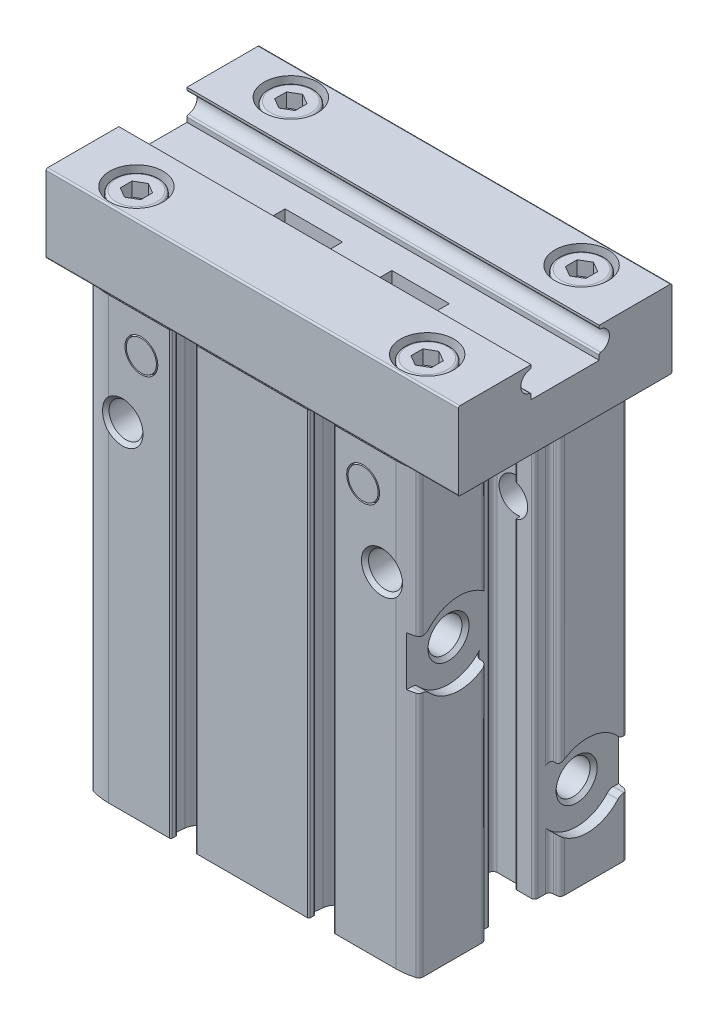
from build123d import *

# Parameters (mm, degrees)
BOSS_EXTRUDE1_DEPTH      = 53.6
HOLE1_D                  = 4.134
HOLE1_DEPTH              = 10.4
HOLE1_CSINK_D            = 5
HOLE1_CSINK_ANGLE        = 90
CUT_EXTRUDE1_DEPTH       = 1.3
CUT_EXTRUDE2_DEPTH       = 1.3
CUT_EXTRUDE3_DEPTH       = 53.6
CUT_EXTRUDE4_DEPTH       = 53.6
BOSS_EXTRUDE2_DEPTH      = 25.1
BOSS_EXTRUDE2_DEPTH_BACK = 25.1
SKETCH25_R               = 1
BOSS_EXTRUDE3_DEPTH      = 1
CUT_EXTRUDE5_DEPTH       = 53.6
CUT_EXTRUDE6_DEPTH       = 53.6
CUT_EXTRUDE7_DEPTH       = 53.6
CUT_EXTRUDE8_DEPTH       = 53.6
SKETCH32_W               = 2
SKETCH32_H               = 26
SKETCH33_W               = 2
SKETCH33_H               = 26
CUT_EXTRUDE9_DEPTH       = 1
CUT_EXTRUDE9_DEPTH_BACK  = 1
SKETCH36_W               = 7
SKETCH36_H               = 2
CUT_EXTRUDE10_DEPTH      = 1
CUT_EXTRUDE10_DEPTH_BACK = 1
SKETCH37_W               = 7
SKETCH37_H               = 2
CUT_EXTRUDE11_DEPTH      = 1.7
LPATTERN1_COUNT          = 2
LPATTERN1_PITCH          = 18.8
LPATTERN1_COUNT_DIR2     = 2
LPATTERN1_PITCH_DIR2     = 35.4


with BuildPart() as part:
    # Sketch1 → Boss-Extrude1 (new body)
    with BuildSketch(Plane(origin=(0, 0, 0), x_dir=(1, 0, 0), z_dir=(0, 1, 0))):
        with BuildLine():
            Line((-17.5, -13), (17.5, -13))
            ThreePointArc((17.5, -13), (18.582771866, -12.921428777), (19.642857143, -12.687361356))
            ThreePointArc((19.642857143, -12.687361356), (19.900891863, -12.507011085), (20, -12.208203933))
            Line((20, -12.208203933), (20, 12.208203933))
            ThreePointArc((20, 12.208203933), (19.900891863, 12.507011085), (19.642857143, 12.687361356))
            ThreePointArc((19.642857143, 12.687361356), (18.582771866, 12.921428777), (17.5, 13))
            Line((17.5, 13), (-17.5, 13))
            ThreePointArc((-17.5, 13), (-18.582771866, 12.921428777), (-19.642857143, 12.687361356))
            ThreePointArc((-19.642857143, 12.687361356), (-19.900891863, 12.507011085), (-20, 12.208203933))
            Line((-20, 12.208203933), (-20, -12.208203933))
            ThreePointArc((-20, -12.208203933), (-19.900891863, -12.507011085), (-19.642857143, -12.687361356))
            ThreePointArc((-19.642857143, -12.687361356), (-18.582771866, -12.921428777), (-17.5, -13))
        make_face()
    extrude(amount=BOSS_EXTRUDE1_DEPTH)

    # Sketch2 → Cut-Revolve1 (revolve, cut)
    with BuildSketch(Plane(origin=(0, 41, 0), x_dir=(1, 0, 0), z_dir=(0, 1, 0))):
        Polygon((15.8, -2.6), (17.867, -2.6), (17.867, -12.567), (18.3, -13), (15.8, -13), align=None)
    revolve(axis=Axis((15.8, 41, 13), (0, 0, -1)), mode=Mode.SUBTRACT)

    # Sketch3 → Cut-Revolve2 (revolve, cut)
    with BuildSketch(Plane(origin=(0, 41, 0), x_dir=(1, 0, 0), z_dir=(0, 1, 0))):
        Polygon((-15.8, -2.6), (-13.733, -2.6), (-13.733, -12.567), (-13.3, -13), (-15.8, -13), align=None)
    revolve(axis=Axis((-15.8, 41, 13), (0, 0, -1)), mode=Mode.SUBTRACT)

    # Hole1
    with Locations(Plane(origin=(0, 0, -13), x_dir=(-1, 0, 0), z_dir=(0, 0, -1))):
        with Locations((-15.8, 41)):
            CounterSinkHole(HOLE1_D / 2, HOLE1_CSINK_D / 2, depth=HOLE1_DEPTH, counter_sink_angle=HOLE1_CSINK_ANGLE)

    # Sketch6 → Cut-Revolve3 (revolve, cut)
    with BuildSketch(Plane(origin=(0, 41, 0), x_dir=(1, 0, 0), z_dir=(0, 1, 0))):
        Polygon((-15.8, 13), (-13.3, 13), (-13.733, 12.567), (-13.733, 2.6), (-15.8, 2.6), align=None)
    revolve(axis=Axis((-15.8, 41, -2.6), (0, 0, -1)), mode=Mode.SUBTRACT)

    # Sketch7 → Cut-Extrude1 (cut)
    with BuildSketch(Plane(origin=(20, 0, 0), x_dir=(0, 0, -1), z_dir=(1, 0, 0))):
        with BuildLine():
            Line((12.272135955, 7.2), (14, 7.2))
            Line((14, 7.2), (14, 13.2))
            Line((14, 13.2), (12.272135955, 13.2))
            ThreePointArc((12.272135955, 13.2), (11.863887665, 13.287129071), (11.526779962, 13.533333333))
            ThreePointArc((11.526779962, 13.533333333), (2.8, 10.2), (11.526779962, 6.866666667))
            ThreePointArc((11.526779962, 6.866666667), (11.863887665, 7.112870929), (12.272135955, 7.2))
        make_face()
    extrude(amount=-CUT_EXTRUDE1_DEPTH, mode=Mode.SUBTRACT)

    # Sketch8 → Cut-Extrude2 (cut)
    with BuildSketch(Plane(origin=(20, 0, 0), x_dir=(0, 0, -1), z_dir=(1, 0, 0))):
        with BuildLine():
            Line((-14, 30), (-12.272135955, 30))
            ThreePointArc((-12.272135955, 30), (-11.863887665, 29.912870929), (-11.526779962, 29.666666667))
            ThreePointArc((-11.526779962, 29.666666667), (-2.8, 33), (-11.526779962, 36.333333333))
            ThreePointArc((-11.526779962, 36.333333333), (-11.863887665, 36.087129071), (-12.272135955, 36))
            Line((-12.272135955, 36), (-14, 36))
            Line((-14, 36), (-14, 30))
        make_face()
    extrude(amount=-CUT_EXTRUDE2_DEPTH, mode=Mode.SUBTRACT)

    # Sketch9 → Cut-Revolve4 (revolve, cut)
    with BuildSketch(Plane.XY.offset(-7.8)):
        Polygon((12.7, 10.2), (12.7, 12.267), (18.267, 12.267), (18.7, 12.7), (18.7, 10.2), align=None)
    revolve(axis=Axis((18.7, 10.2, -7.8), (-1, 0, 0)), mode=Mode.SUBTRACT)

    # Sketch10 → Cut-Revolve5 (revolve, cut)
    with BuildSketch(Plane.XY.offset(7.8)):
        Polygon((12.7, 33), (12.7, 35.067), (18.267, 35.067), (18.7, 35.5), (18.7, 33), align=None)
    revolve(axis=Axis((18.7, 33, 7.8), (-1, 0, 0)), mode=Mode.SUBTRACT)

    # Sketch11 → Cut-Revolve6 (revolve, cut)
    with BuildSketch(Plane(origin=(0, 33, 0), x_dir=(1, 0, 0), z_dir=(0, 1, 0))):
        with BuildLine():
            Line((-20, 7), (-20, 11.2))
            ThreePointArc((-20, 11.2), (-19.941421356, 11.058578644), (-19.8, 11))
            Line((-19.8, 11), (-18.7, 11))
            Line((-18.7, 11), (-18.7, 7))
            Line((-18.7, 7), (-20, 7))
        make_face()
    revolve(axis=Axis((-18.7, 33, -7), (-1, 0, 0)), mode=Mode.SUBTRACT)

    # Sketch12 → Cut-Revolve7 (revolve, cut)
    with BuildSketch(Plane(origin=(0, 33, 0), x_dir=(1, 0, 0), z_dir=(0, 1, 0))):
        with BuildLine():
            Line((-20, -7), (-20, -2.8))
            ThreePointArc((-20, -2.8), (-19.941421356, -2.941421356), (-19.8, -3))
            Line((-19.8, -3), (-18.7, -3))
            Line((-18.7, -3), (-18.7, -7))
            Line((-18.7, -7), (-20, -7))
        make_face()
    revolve(axis=Axis((-18.7, 33, 7), (-1, 0, 0)), mode=Mode.SUBTRACT)

    # Sketch13 → Cut-Revolve8 (revolve, cut)
    with BuildSketch(Plane(origin=(0, 33, 0), x_dir=(1, 0, 0), z_dir=(0, 1, 0))):
        Polygon((-18.7, 7), (-18.7, 9.5), (-18.267, 9.067), (-10.7, 9.067), (-10.7, 7), align=None)
    revolve(axis=Axis((-10.7, 33, -7), (-1, 0, 0)), mode=Mode.SUBTRACT)

    # Sketch14 → Cut-Revolve9 (revolve, cut)
    with BuildSketch(Plane(origin=(0, 33, 0), x_dir=(1, 0, 0), z_dir=(0, 1, 0))):
        Polygon((-18.7, -7), (-18.7, -4.5), (-18.267, -4.933), (-10.7, -4.933), (-10.7, -7), align=None)
    revolve(axis=Axis((-10.7, 33, 7), (-1, 0, 0)), mode=Mode.SUBTRACT)

    # Sketch15 → Cut-Revolve10 (revolve, cut)
    with BuildSketch(Plane(origin=(0, 23, 0), x_dir=(1, 0, 0), z_dir=(0, 1, 0))):
        Polygon((-20, 8), (-20, 10.2), (-19.8, 10), (-16, 10), (-16, 8), align=None)
    revolve(axis=Axis((-16, 23, -8), (-1, 0, 0)), mode=Mode.SUBTRACT)

    # Sketch16 → Cut-Revolve11 (revolve, cut)
    with BuildSketch(Plane(origin=(0, 23, 0), x_dir=(1, 0, 0), z_dir=(0, 1, 0))):
        Polygon((-20, -8), (-20, -5.8), (-19.8, -6), (-16, -6), (-16, -8), align=None)
    revolve(axis=Axis((-16, 23, 8), (-1, 0, 0)), mode=Mode.SUBTRACT)

    # Sketch17 → Cut-Extrude3 (cut)
    with BuildSketch(Plane(origin=(0, 0, 0), x_dir=(1, 0, 0), z_dir=(0, 1, 0))):
        with BuildLine():
            Line((-19.5, -4.5), (-19.2, -4.5))
            ThreePointArc((-19.2, -4.5), (-18.846446609, -4.353553391), (-18.7, -4))
            Line((-18.7, -4), (-18.7, -3.075))
            ThreePointArc((-18.7, -3.075), (-18.582842712, -2.792157288), (-18.3, -2.675))
            Line((-18.3, -2.675), (-16.55, -2.675))
            ThreePointArc((-16.55, -2.675), (-16.408578644, -2.733578644), (-16.35, -2.875))
            Line((-16.35, -2.875), (-16.35, -3.125))
            ThreePointArc((-16.35, -3.125), (-16.291421356, -3.266421356), (-16.15, -3.325))
            Line((-16.15, -3.325), (-13.5, -3.325))
            ThreePointArc((-13.5, -3.325), (-13.146446609, -3.178553391), (-13, -2.825))
            Line((-13, -2.825), (-13, 2.825))
            ThreePointArc((-13, 2.825), (-13.146446609, 3.178553391), (-13.5, 3.325))
            Line((-13.5, 3.325), (-16.15, 3.325))
            ThreePointArc((-16.15, 3.325), (-16.291421356, 3.266421356), (-16.35, 3.125))
            Line((-16.35, 3.125), (-16.35, 2.875))
            ThreePointArc((-16.35, 2.875), (-16.408578644, 2.733578644), (-16.55, 2.675))
            Line((-16.55, 2.675), (-18.3, 2.675))
            ThreePointArc((-18.3, 2.675), (-18.582842712, 2.792157288), (-18.7, 3.075))
            Line((-18.7, 3.075), (-18.7, 4))
            ThreePointArc((-18.7, 4), (-18.846446609, 4.353553391), (-19.2, 4.5))
            Line((-19.2, 4.5), (-19.5, 4.5))
            ThreePointArc((-19.5, 4.5), (-19.853553391, 4.646446609), (-20, 5))
            Line((-20, 5), (-20, -5))
            ThreePointArc((-20, -5), (-19.853553391, -4.646446609), (-19.5, -4.5))
        make_face()
    extrude(amount=CUT_EXTRUDE3_DEPTH, mode=Mode.SUBTRACT)

    # Sketch18 → Cut-Extrude4 (cut)
    with BuildSketch(Plane(origin=(0, 0, 0), x_dir=(1, 0, 0), z_dir=(0, 1, 0))):
        with BuildLine():
            Line((13, 2.825), (13, -2.825))
            ThreePointArc((13, -2.825), (13.146446609, -3.178553391), (13.5, -3.325))
            Line((13.5, -3.325), (16.15, -3.325))
            ThreePointArc((16.15, -3.325), (16.291421356, -3.266421356), (16.35, -3.125))
            Line((16.35, -3.125), (16.35, -2.875))
            ThreePointArc((16.35, -2.875), (16.408578644, -2.733578644), (16.55, -2.675))
            Line((16.55, -2.675), (18.3, -2.675))
            ThreePointArc((18.3, -2.675), (18.582842712, -2.792157288), (18.7, -3.075))
            Line((18.7, -3.075), (18.7, -4))
            ThreePointArc((18.7, -4), (18.846446609, -4.353553391), (19.2, -4.5))
            Line((19.2, -4.5), (19.5, -4.5))
            ThreePointArc((19.5, -4.5), (19.853553391, -4.646446609), (20, -5))
            Line((20, -5), (20, 5))
            ThreePointArc((20, 5), (19.853553391, 4.646446609), (19.5, 4.5))
            Line((19.5, 4.5), (19.2, 4.5))
            ThreePointArc((19.2, 4.5), (18.846446609, 4.353553391), (18.7, 4))
            Line((18.7, 4), (18.7, 3.075))
            ThreePointArc((18.7, 3.075), (18.582842712, 2.792157288), (18.3, 2.675))
            Line((18.3, 2.675), (16.55, 2.675))
            ThreePointArc((16.55, 2.675), (16.408578644, 2.733578644), (16.35, 2.875))
            Line((16.35, 2.875), (16.35, 3.125))
            ThreePointArc((16.35, 3.125), (16.291421356, 3.266421356), (16.15, 3.325))
            Line((16.15, 3.325), (13.5, 3.325))
            ThreePointArc((13.5, 3.325), (13.146446609, 3.178553391), (13, 2.825))
        make_face()
    extrude(amount=CUT_EXTRUDE4_DEPTH, mode=Mode.SUBTRACT)

    # Sketch19 → Boss-Extrude2 (add, two sides: drawn at the far end of the back side and taken through both)
    with BuildSketch(Plane(origin=(0, 0, 0), x_dir=(0, 0, -1), z_dir=(1, 0, 0)).offset(-BOSS_EXTRUDE2_DEPTH_BACK)):
        with BuildLine():
            Line((-13, 62.9), (-13, 53.8))
            ThreePointArc((-13, 53.8), (-12.941421356, 53.658578644), (-12.8, 53.6))
            Line((-12.8, 53.6), (12.8, 53.6))
            ThreePointArc((12.8, 53.6), (12.941421356, 53.658578644), (13, 53.8))
            Line((13, 53.8), (13, 62.9))
            ThreePointArc((13, 62.9), (12.941421356, 63.041421356), (12.8, 63.1))
            Line((12.8, 63.1), (4.15, 63.1))
            Line((4.15, 63.1), (4.15, 62.836140662))
            ThreePointArc((4.15, 62.836140662), (4.199140394, 62.704834229), (4.322413793, 62.638052295))
            ThreePointArc((4.322413793, 62.638052295), (5.4, 61.4), (4.322413793, 60.161947705))
            ThreePointArc((4.322413793, 60.161947705), (4.199140394, 60.095165771), (4.15, 59.963859338))
            Line((4.15, 59.963859338), (4.15, 59.4))
            Line((4.15, 59.4), (-4.15, 59.4))
            Line((-4.15, 59.4), (-4.15, 59.963859338))
            ThreePointArc((-4.15, 59.963859338), (-4.199140394, 60.095165771), (-4.322413793, 60.161947705))
            ThreePointArc((-4.322413793, 60.161947705), (-5.4, 61.4), (-4.322413793, 62.638052295))
            ThreePointArc((-4.322413793, 62.638052295), (-4.199140394, 62.704834229), (-4.15, 62.836140662))
            Line((-4.15, 62.836140662), (-4.15, 63.1))
            Line((-4.15, 63.1), (-12.8, 63.1))
            ThreePointArc((-12.8, 63.1), (-12.941421356, 63.041421356), (-13, 62.9))
        make_face()
    extrude(amount=BOSS_EXTRUDE2_DEPTH + BOSS_EXTRUDE2_DEPTH_BACK)

    # Sketch20 → Cut-Revolve12 (revolve, cut)
    with BuildSketch(Plane.XY.offset(8.3)):
        Polygon((15, 10), (17.067, 10), (17.067, 0.433), (17.5, 0), (15, 0), align=None)
    revolve(axis=Axis((15, 0, 8.3), (0, 1, 0)), mode=Mode.SUBTRACT)

    # Sketch21 → Cut-Revolve13 (revolve, cut)
    with BuildSketch(Plane.XY.offset(-8.3)):
        Polygon((-15, 10), (-12.933, 10), (-12.933, 0.433), (-12.5, 0), (-15, 0), align=None)
    revolve(axis=Axis((-15, 0, -8.3), (0, 1, 0)), mode=Mode.SUBTRACT)

    # Sketch22 → Cut-Revolve14 (revolve, cut)
    with BuildSketch(Plane.XY.offset(8.5)):
        Polygon((-15.5, 4), (-13.5, 4), (-13.5, 0.2), (-13.3, 0), (-15.5, 0), align=None)
    revolve(axis=Axis((-15.5, 0, 8.5), (0, 1, 0)), mode=Mode.SUBTRACT)

    # Sketch23 → Cut-Revolve15 (revolve, cut)
    with BuildSketch(Plane.XY.offset(-8.5)):
        Polygon((15.5, 4), (17.5, 4), (17.5, 0.2), (17.7, 0), (15.5, 0), align=None)
    revolve(axis=Axis((15.5, 0, -8.5), (0, 1, 0)), mode=Mode.SUBTRACT)

    # Sketch24 → Cut-Revolve16 (revolve, cut)
    with BuildSketch(Plane.XY):
        Polygon((0, 4), (11, 4), (11, 3), (10.5, 3), (10.5, 0.4), (10.730940108, 0), (0, 0), align=None)
    revolve(axis=Axis((0, 0, 0), (0, 1, 0)), mode=Mode.SUBTRACT)

    # Sketch25 → Boss-Extrude3 (add)
    with BuildSketch(Plane(origin=(0, 3, 0), x_dir=(1, 0, 0), z_dir=(0, 1, 0))):
        with BuildLine():
            Line((10.73498952, -2.4), (6.41641989, -2.4))
            ThreePointArc((6.41641989, -2.4), (5.922520907, -3.569763083), (5.243096089, -4.642453063))
            Line((5.243096089, -4.642453063), (6.438731142, -5.701117546))
            ThreePointArc((6.438731142, -5.701117546), (-8.6, 0), (6.438731142, 5.701117546))
            Line((6.438731142, 5.701117546), (5.243096089, 4.642453063))
            ThreePointArc((5.243096089, 4.642453063), (5.922520907, 3.569763083), (6.41641989, 2.4))
            Line((6.41641989, 2.4), (10.73498952, 2.4))
            ThreePointArc((10.73498952, 2.4), (-11, 0), (10.73498952, -2.4))
        make_face()
        with Locations((7.736278175, 4.4)):
            Circle(SKETCH25_R, mode=Mode.SUBTRACT)
        with Locations((7.736278175, -4.4)):
            Circle(SKETCH25_R, mode=Mode.SUBTRACT)
    extrude(amount=BOSS_EXTRUDE3_DEPTH)

    # Sketch26 → Cut-Revolve17 (revolve, cut)
    with BuildSketch(Plane(origin=(0, 16, 0), x_dir=(1, 0, 0), z_dir=(0, 1, 0))):
        Polygon((14.2, 13), (16.4, 13), (16.2, 12.8), (16.2, 9), (14.2, 9), align=None)
    revolve(axis=Axis((14.2, 16, -9), (0, 0, -1)), mode=Mode.SUBTRACT)

    # Sketch27 → Cut-Revolve18 (revolve, cut)
    with BuildSketch(Plane(origin=(0, 16, 0), x_dir=(1, 0, 0), z_dir=(0, 1, 0))):
        Polygon((-14.2, 13), (-12, 13), (-12.2, 12.8), (-12.2, 9), (-14.2, 9), align=None)
    revolve(axis=Axis((-14.2, 16, -9), (0, 0, -1)), mode=Mode.SUBTRACT)

    # Sketch28 → Cut-Extrude5 (cut)
    with BuildSketch(Plane(origin=(0, 0, 0), x_dir=(1, 0, 0), z_dir=(0, 1, 0))):
        with BuildLine():
            Line((6.512975195, 11.970274713), (6.608936703, 11.010856853))
            ThreePointArc((6.608936703, 11.010856853), (8.4, 9.39), (10.191063297, 11.010856853))
            Line((10.191063297, 11.010856853), (10.287024805, 11.970274713))
            ThreePointArc((10.287024805, 11.970274713), (10.238303244, 12.122142673), (10.094008886, 12.190089754))
            ThreePointArc((10.094008886, 12.190089754), (9.956476095, 12.250712927), (9.9, 12.39))
            Line((9.9, 12.39), (9.9, 12.8))
            ThreePointArc((9.9, 12.8), (9.958578644, 12.941421356), (10.1, 13))
            Line((10.1, 13), (6.7, 13))
            ThreePointArc((6.7, 13), (6.841421356, 12.941421356), (6.9, 12.8))
            Line((6.9, 12.8), (6.9, 12.39))
            ThreePointArc((6.9, 12.39), (6.843523905, 12.250712927), (6.705991114, 12.190089754))
            ThreePointArc((6.705991114, 12.190089754), (6.561696756, 12.122142673), (6.512975195, 11.970274713))
        make_face()
    extrude(amount=CUT_EXTRUDE5_DEPTH, mode=Mode.SUBTRACT)

    # Sketch29 → Cut-Extrude6 (cut)
    with BuildSketch(Plane(origin=(0, 0, 0), x_dir=(1, 0, 0), z_dir=(0, 1, 0))):
        with BuildLine():
            Line((-10.288022145, 11.980246069), (-10.191063297, 11.010856853))
            ThreePointArc((-10.191063297, 11.010856853), (-8.4, 9.39), (-6.608936703, 11.010856853))
            Line((-6.608936703, 11.010856853), (-6.511977855, 11.980246069))
            ThreePointArc((-6.511977855, 11.980246069), (-6.560864116, 12.13230136), (-6.705492444, 12.200075432))
            ThreePointArc((-6.705492444, 12.200075432), (-6.843350076, 12.260534034), (-6.9, 12.4))
            Line((-6.9, 12.4), (-6.9, 12.8))
            ThreePointArc((-6.9, 12.8), (-6.841421356, 12.941421356), (-6.7, 13))
            Line((-6.7, 13), (-10.1, 13))
            ThreePointArc((-10.1, 13), (-9.958578644, 12.941421356), (-9.9, 12.8))
            Line((-9.9, 12.8), (-9.9, 12.4))
            ThreePointArc((-9.9, 12.4), (-9.956649924, 12.260534034), (-10.094507556, 12.200075432))
            ThreePointArc((-10.094507556, 12.200075432), (-10.239135884, 12.13230136), (-10.288022145, 11.980246069))
        make_face()
    extrude(amount=CUT_EXTRUDE6_DEPTH, mode=Mode.SUBTRACT)

    # Sketch30 → Cut-Extrude7 (cut)
    with BuildSketch(Plane(origin=(0, 0, 0), x_dir=(1, 0, 0), z_dir=(0, 1, 0))):
        with BuildLine():
            Line((6.9, -12.4), (6.9, -12.8))
            ThreePointArc((6.9, -12.8), (6.841421356, -12.941421356), (6.7, -13))
            Line((6.7, -13), (10.1, -13))
            ThreePointArc((10.1, -13), (9.958578644, -12.941421356), (9.9, -12.8))
            Line((9.9, -12.8), (9.9, -12.4))
            ThreePointArc((9.9, -12.4), (9.956649924, -12.260534034), (10.094507556, -12.200075432))
            ThreePointArc((10.094507556, -12.200075432), (10.239135884, -12.13230136), (10.288022145, -11.980246069))
            Line((10.288022145, -11.980246069), (10.191063297, -11.010856853))
            ThreePointArc((10.191063297, -11.010856853), (8.4, -9.39), (6.608936703, -11.010856853))
            Line((6.608936703, -11.010856853), (6.511977855, -11.980246069))
            ThreePointArc((6.511977855, -11.980246069), (6.560864116, -12.13230136), (6.705492444, -12.200075432))
            ThreePointArc((6.705492444, -12.200075432), (6.843350076, -12.260534034), (6.9, -12.4))
        make_face()
    extrude(amount=CUT_EXTRUDE7_DEPTH, mode=Mode.SUBTRACT)

    # Sketch31 → Cut-Extrude8 (cut)
    with BuildSketch(Plane(origin=(0, 0, 0), x_dir=(1, 0, 0), z_dir=(0, 1, 0))):
        with BuildLine():
            Line((-9.9, -12.4), (-9.9, -12.8))
            ThreePointArc((-9.9, -12.8), (-9.958578644, -12.941421356), (-10.1, -13))
            Line((-10.1, -13), (-6.7, -13))
            ThreePointArc((-6.7, -13), (-6.841421356, -12.941421356), (-6.9, -12.8))
            Line((-6.9, -12.8), (-6.9, -12.4))
            ThreePointArc((-6.9, -12.4), (-6.843350076, -12.260534034), (-6.705492444, -12.200075432))
            ThreePointArc((-6.705492444, -12.200075432), (-6.560864116, -12.13230136), (-6.511977855, -11.980246069))
            Line((-6.511977855, -11.980246069), (-6.608936703, -11.010856853))
            ThreePointArc((-6.608936703, -11.010856853), (-8.4, -9.39), (-10.191063297, -11.010856853))
            Line((-10.191063297, -11.010856853), (-10.288022145, -11.980246069))
            ThreePointArc((-10.288022145, -11.980246069), (-10.239135884, -12.13230136), (-10.094507556, -12.200075432))
            ThreePointArc((-10.094507556, -12.200075432), (-9.956649924, -12.260534034), (-9.9, -12.4))
        make_face()
    extrude(amount=CUT_EXTRUDE8_DEPTH, mode=Mode.SUBTRACT)

    # Sketch32 → Cut-Revolve19 (revolve, cut)
    with BuildSketch(Plane(origin=(0, 49.16, 0), x_dir=(1, 0, 0), z_dir=(0, 1, 0))):
        with Locations((14.5, 0)):
            Rectangle(SKETCH32_W, SKETCH32_H)
    revolve(axis=Axis((13.5, 49.16, 13), (0, 0, -1)), mode=Mode.SUBTRACT)

    # Sketch33 → Cut-Revolve20 (revolve, cut)
    with BuildSketch(Plane(origin=(0, 49.16, 0), x_dir=(1, 0, 0), z_dir=(0, 1, 0))):
        with Locations((-12.5, 0)):
            Rectangle(SKETCH33_W, SKETCH33_H)
    revolve(axis=Axis((-13.5, 49.16, 13), (0, 0, -1)), mode=Mode.SUBTRACT)

    # Sketch34 → Revolve1 (revolve)
    with BuildSketch(Plane(origin=(0, 49.16, 0), x_dir=(1, 0, 0), z_dir=(0, 1, 0))):
        Polygon((13.5, 13), (15.331192009, 13), (15.5, 12.37), (15.5, -12.37), (15.331192009, -13), (13.5, -13), align=None)
    revolve(axis=Axis((13.5, 49.16, 13), (0, 0, -1)))

    # Sketch35 → Revolve2 (revolve)
    with BuildSketch(Plane(origin=(0, 49.16, 0), x_dir=(1, 0, 0), z_dir=(0, 1, 0))):
        Polygon((-13.5, 13), (-11.668807991, 13), (-11.5, 12.37), (-11.5, -12.37), (-11.668807991, -13), (-13.5, -13), align=None)
    revolve(axis=Axis((-13.5, 49.16, 13), (0, 0, -1)))

    # Sketch36 → Cut-Extrude9 (cut, two sides: drawn at the far end of the back side and taken through both)
    with BuildSketch(Plane.XY.offset(-CUT_EXTRUDE9_DEPTH_BACK)):
        with Locations((6.5, 58.4)):
            Rectangle(SKETCH36_W, SKETCH36_H)
    extrude(amount=CUT_EXTRUDE9_DEPTH + CUT_EXTRUDE9_DEPTH_BACK, mode=Mode.SUBTRACT)

    # Sketch37 → Cut-Extrude10 (cut, two sides: drawn at the far end of the back side and taken through both)
    with BuildSketch(Plane.XY.offset(-CUT_EXTRUDE10_DEPTH_BACK)):
        with Locations((-6.5, 58.4)):
            Rectangle(SKETCH37_W, SKETCH37_H)
    extrude(amount=CUT_EXTRUDE10_DEPTH + CUT_EXTRUDE10_DEPTH_BACK, mode=Mode.SUBTRACT)

    # Sketch38 → Cut-Revolve21 (revolve, cut)
    with BuildSketch(Plane.XY.offset(9.4)):
        with BuildLine():
            Line((17.7, 63.1), (20.95, 63.1))
            Line((20.95, 63.1), (20.95, 59.7))
            Line((20.95, 59.7), (20.45, 59.7))
            Line((20.45, 59.7), (20.45, 62.4))
            ThreePointArc((20.45, 62.4), (20.362132034, 62.612132034), (20.15, 62.7))
            Line((20.15, 62.7), (17.7, 62.7))
            Line((17.7, 62.7), (17.7, 63.1))
        make_face()
    revolve(axis=Axis((17.7, 59.7, 9.4), (0, 1, 0)), mode=Mode.SUBTRACT)

    # Sketch39 → Cut-Revolve22 (revolve, cut)
    with BuildSketch(Plane.XY.offset(9.4)):
        with BuildLine():
            Line((-17.7, 63.1), (-14.45, 63.1))
            Line((-14.45, 63.1), (-14.45, 59.7))
            Line((-14.45, 59.7), (-14.95, 59.7))
            Line((-14.95, 59.7), (-14.95, 62.4))
            ThreePointArc((-14.95, 62.4), (-15.037867966, 62.612132034), (-15.25, 62.7))
            Line((-15.25, 62.7), (-17.7, 62.7))
            Line((-17.7, 62.7), (-17.7, 63.1))
        make_face()
    revolve(axis=Axis((-17.7, 59.7, 9.4), (0, 1, 0)), mode=Mode.SUBTRACT)

    # Sketch40 → Cut-Revolve23 (revolve, cut)
    with BuildSketch(Plane.XY.offset(-9.4)):
        with BuildLine():
            Line((17.7, 63.1), (20.95, 63.1))
            Line((20.95, 63.1), (20.95, 59.7))
            Line((20.95, 59.7), (20.45, 59.7))
            Line((20.45, 59.7), (20.45, 62.4))
            ThreePointArc((20.45, 62.4), (20.362132034, 62.612132034), (20.15, 62.7))
            Line((20.15, 62.7), (17.7, 62.7))
            Line((17.7, 62.7), (17.7, 63.1))
        make_face()
    revolve(axis=Axis((17.7, 59.7, -9.4), (0, 1, 0)), mode=Mode.SUBTRACT)

    # Sketch41 → Cut-Revolve24 (revolve, cut)
    with BuildSketch(Plane.XY.offset(-9.4)):
        with BuildLine():
            Line((-17.7, 63.1), (-14.45, 63.1))
            Line((-14.45, 63.1), (-14.45, 59.7))
            Line((-14.45, 59.7), (-14.95, 59.7))
            Line((-14.95, 59.7), (-14.95, 62.4))
            ThreePointArc((-14.95, 62.4), (-15.037867966, 62.612132034), (-15.25, 62.7))
            Line((-15.25, 62.7), (-17.7, 62.7))
            Line((-17.7, 62.7), (-17.7, 63.1))
        make_face()
    revolve(axis=Axis((-17.7, 59.7, -9.4), (0, 1, 0)), mode=Mode.SUBTRACT)

    # Sketch42 → Cut-Extrude11 (cut)
    with BuildSketch(Plane(origin=(0, 62.7, 0), x_dir=(1, 0, 0), z_dir=(0, 1, 0))):
        Polygon((16.45, -10.121687836), (17.7, -10.843375673), (18.95, -10.121687836), (18.95, -8.678312164), (17.7, -7.956624327), (16.45, -8.678312164), align=None)
    cut_extrude11 = extrude(amount=-CUT_EXTRUDE11_DEPTH, mode=Mode.SUBTRACT)

    # LPattern1: Cut-Extrude11 2 × 2
    with Locations(*[(-j * LPATTERN1_PITCH_DIR2, 0, -i * LPATTERN1_PITCH) for i in range(LPATTERN1_COUNT) for j in range(LPATTERN1_COUNT_DIR2) if (i, j) != (0, 0)]):
        add(cut_extrude11, mode=Mode.SUBTRACT)


solid = part.part
